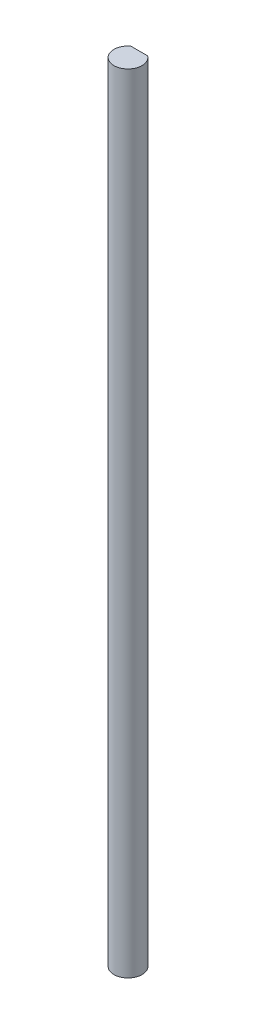
from build123d import *

# Parameters (mm, degrees)
BOSS_EXTRUDE1_DEPTH = 177.8


with BuildPart() as part:
    # Sketch1 → Boss-Extrude1 (new body)
    with BuildSketch(Plane(origin=(0, 0, 0), x_dir=(1, 0, 0), z_dir=(0, 1, 0))):
        with BuildLine():
            Line((-1.905, 2.54), (1.905, 2.54))
            ThreePointArc((1.905, 2.54), (0, -3.175), (-1.905, 2.54))
        make_face()
    extrude(amount=BOSS_EXTRUDE1_DEPTH)


solid = part.part
